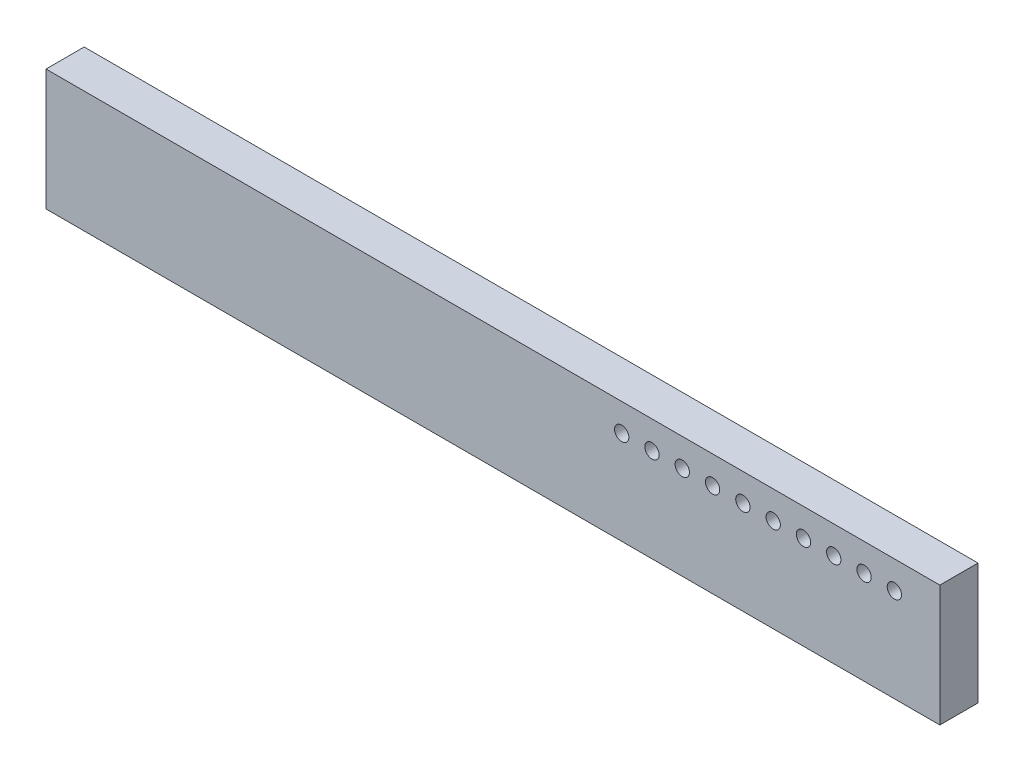
from build123d import *

# Parameters (mm, degrees)
SKETCH1_W           = 37.465
SKETCH1_H           = 5.08
BOSS_EXTRUDE1_DEPTH = 1.6
SKETCH2_R           = 0.3
CUT_EXTRUDE1_DEPTH  = 2.6


with BuildPart() as part:
    # Sketch1 → Boss-Extrude1 (new body)
    with BuildSketch(Plane.XY):
        Rectangle(SKETCH1_W, SKETCH1_H)
    extrude(amount=BOSS_EXTRUDE1_DEPTH)

    # Sketch2 → Cut-Extrude1 (cut, through all)
    with BuildSketch(Plane.XY.offset(1.6)):
        with Locations((16.8275, 1.38)):
            Circle(SKETCH2_R)
        with Locations((15.5575, 1.38)):
            Circle(SKETCH2_R)
        with Locations((14.2875, 1.38)):
            Circle(SKETCH2_R)
        with Locations((13.0175, 1.38)):
            Circle(SKETCH2_R)
        with Locations((11.7475, 1.38)):
            Circle(SKETCH2_R)
        with Locations((10.4775, 1.38)):
            Circle(SKETCH2_R)
        with Locations((9.2075, 1.38)):
            Circle(SKETCH2_R)
        with Locations((7.9375, 1.38)):
            Circle(SKETCH2_R)
        with Locations((6.6675, 1.38)):
            Circle(SKETCH2_R)
        with Locations((5.3975, 1.38)):
            Circle(SKETCH2_R)
    extrude(amount=-CUT_EXTRUDE1_DEPTH, mode=Mode.SUBTRACT)


solid = part.part
